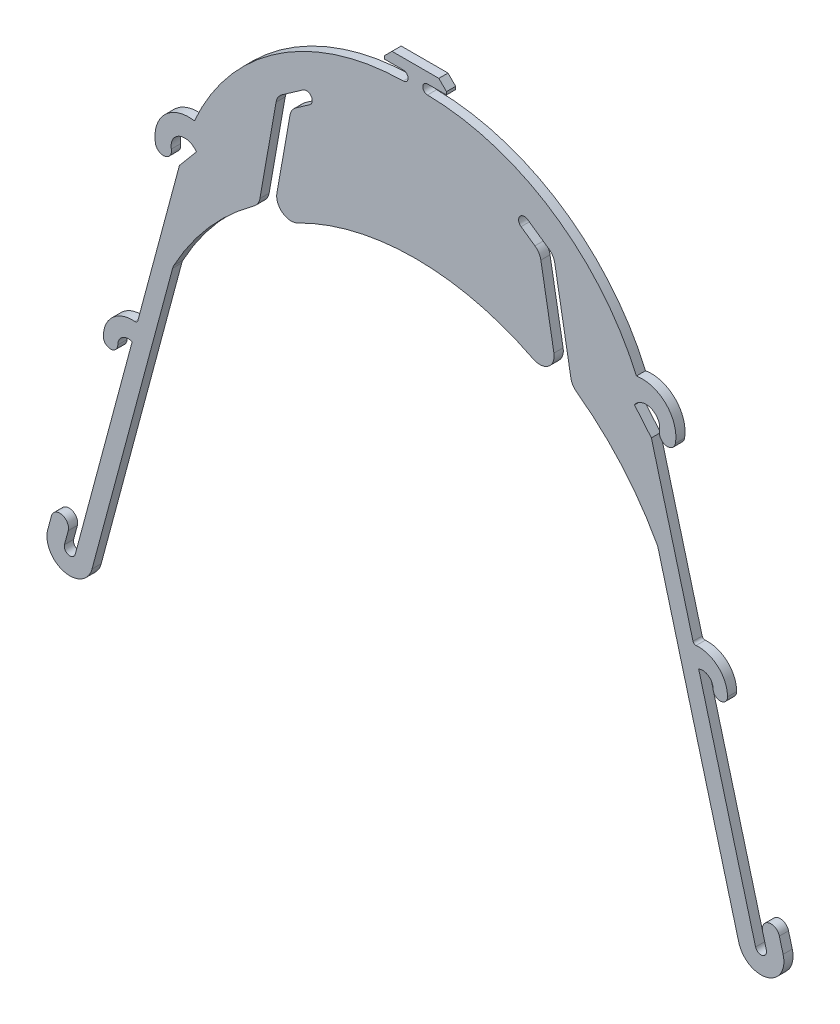
from build123d import *

# Parameters (mm, degrees)
BOSS_EXTRUDE1_DEPTH = 3.175


with BuildPart() as part:
    # Sketch1 → Boss-Extrude1 (new body)
    with BuildSketch(Plane.XY):
        with BuildLine():
            Line((-8.1, 0), (8.1, 0))
            Line((8.1, 0), (10.75, -2.65))
            Line((10.75, -2.65), (10.75, -3.65))
            Line((10.75, -3.65), (4.2, -3.65))
            ThreePointArc((4.2, -3.65), (2.550037108, -5.288934004), (4.177868505, -6.949851568))
            ThreePointArc((4.177868505, -6.949851568), (47.407650937, -20.329895347), (76.461639413, -55.024353322))
            ThreePointArc((76.461639413, -55.024353322), (86.688165284, -58.25355516), (89.960911147, -68.466229169))
            ThreePointArc((89.960911147, -68.466229169), (86.704969014, -70.755892654), (84.44942629, -67.476221165))
            ThreePointArc((84.44942629, -67.476221165), (81.554604124, -62.18029995), (75.8, -64))
            Line((75.8, -64), (81.646374133, -70.967437377))
            Line((81.646374133, -70.967437377), (96.044354863, -124.701432988))
            ThreePointArc((96.044354863, -124.701432988), (96.437025669, -125.261990951), (97.098218064, -125.438739948))
            ThreePointArc((97.098218064, -125.438739948), (104.73060086, -128.02457671), (107.977591805, -135.4))
            ThreePointArc((107.977591805, -135.4), (105.477591805, -137.9), (102.977591805, -135.4))
            ThreePointArc((102.977591805, -135.4), (101.386328057, -132.386015089), (98, -132))
            Line((98, -132), (117.691047305, -205.487988996))
            ThreePointArc((117.691047305, -205.487988996), (120.056868172, -206.85389631), (121.422775486, -204.488075443))
            Line((121.422775486, -204.488075443), (120.128680261, -199.658446312))
            ThreePointArc((120.128680261, -199.658446312), (122.250000605, -195.984211697), (125.924235219, -198.105532041))
            Line((125.924235219, -198.105532041), (127.218330444, -202.935161172))
            ThreePointArc((127.218330444, -202.935161172), (121.609782443, -212.649451268), (111.895492347, -207.040903266))
            Line((111.895492347, -207.040903266), (84.010461962, -102.9725531))
            ThreePointArc((84.010461962, -102.9725531), (83.826764804, -102.418590939), (83.579767988, -101.889808095))
            ThreePointArc((83.579767988, -101.889808095), (71.468601459, -84.461922175), (55.79064441, -70.157614254))
            ThreePointArc((55.79064441, -70.157614254), (54.487597498, -68.761604863), (53.802955351, -66.978899446))
            Line((53.802955351, -66.978899446), (48.2152775, -35.289603638))
            ThreePointArc((48.2152775, -35.289603638), (47.508195964, -33.471346485), (46.159120917, -32.062084305))
            Line((46.159120917, -32.062084305), (38.847152873, -26.942189162))
            ThreePointArc((38.847152873, -26.942189162), (36.061695911, -27.433340377), (36.552847127, -30.218797339))
            Line((36.552847127, -30.218797339), (41.349143695, -33.577200351))
            ThreePointArc((41.349143695, -33.577200351), (42.698218742, -34.986462531), (43.405300278, -36.804719684))
            Line((43.405300278, -36.804719684), (47.924038765, -62.431759112))
            ThreePointArc((47.924038765, -62.431759112), (45.976650255, -67.317406285), (40.735673212, -67.757894593))
            ThreePointArc((40.735673212, -67.757894593), (20.943431619, -60.476046738), (0, -58))
            ThreePointArc((0, -58), (-20.943431619, -60.476046738), (-40.735673212, -67.757894593))
            ThreePointArc((-40.735673212, -67.757894593), (-45.976650255, -67.317406285), (-47.924038765, -62.431759112))
            Line((-47.924038765, -62.431759112), (-43.405300278, -36.804719684))
            ThreePointArc((-43.405300278, -36.804719684), (-42.698218742, -34.986462531), (-41.349143695, -33.577200351))
            Line((-41.349143695, -33.577200351), (-36.552847127, -30.218797339))
            ThreePointArc((-36.552847127, -30.218797339), (-36.061695911, -27.433340377), (-38.847152873, -26.942189162))
            Line((-38.847152873, -26.942189162), (-46.159120917, -32.062084305))
            ThreePointArc((-46.159120917, -32.062084305), (-47.508195964, -33.471346485), (-48.2152775, -35.289603638))
            Line((-48.2152775, -35.289603638), (-53.802955351, -66.978899446))
            ThreePointArc((-53.802955351, -66.978899446), (-54.487597498, -68.761604863), (-55.79064441, -70.157614254))
            ThreePointArc((-55.79064441, -70.157614254), (-71.468601459, -84.461922175), (-83.579767988, -101.889808095))
            ThreePointArc((-83.579767988, -101.889808095), (-83.826764804, -102.418590939), (-84.010461962, -102.9725531))
            Line((-84.010461962, -102.9725531), (-111.895492347, -207.040903266))
            ThreePointArc((-111.895492347, -207.040903266), (-121.609782443, -212.649451268), (-127.218330444, -202.935161172))
            Line((-127.218330444, -202.935161172), (-125.924235219, -198.105532041))
            ThreePointArc((-125.924235219, -198.105532041), (-122.250000605, -195.984211697), (-120.128680261, -199.658446312))
            Line((-120.128680261, -199.658446312), (-121.422775486, -204.488075443))
            ThreePointArc((-121.422775486, -204.488075443), (-120.056868172, -206.85389631), (-117.691047305, -205.487988996))
            Line((-117.691047305, -205.487988996), (-98, -132))
            ThreePointArc((-98, -132), (-101.386328057, -132.386015089), (-102.977591805, -135.4))
            ThreePointArc((-102.977591805, -135.4), (-105.477591805, -137.9), (-107.977591805, -135.4))
            ThreePointArc((-107.977591805, -135.4), (-104.73060086, -128.02457671), (-97.098218064, -125.438739948))
            ThreePointArc((-97.098218064, -125.438739948), (-96.437025669, -125.261990951), (-96.044354863, -124.701432988))
            Line((-96.044354863, -124.701432988), (-81.646374133, -70.967437377))
            Line((-81.646374133, -70.967437377), (-75.8, -64))
            ThreePointArc((-75.8, -64), (-81.554604124, -62.18029995), (-84.44942629, -67.476221165))
            ThreePointArc((-84.44942629, -67.476221165), (-86.704969014, -70.755892654), (-89.960911147, -68.466229169))
            ThreePointArc((-89.960911147, -68.466229169), (-86.688165284, -58.25355516), (-76.461639413, -55.024353322))
            ThreePointArc((-76.461639413, -55.024353322), (-47.407650937, -20.329895347), (-4.177868505, -6.949851568))
            ThreePointArc((-4.177868505, -6.949851568), (-2.550037108, -5.288934004), (-4.2, -3.65))
            Line((-4.2, -3.65), (-10.75, -3.65))
            Line((-10.75, -3.65), (-10.75, -2.65))
            Line((-10.75, -2.65), (-8.1, 0))
        make_face()
    extrude(amount=BOSS_EXTRUDE1_DEPTH)


solid = part.part
